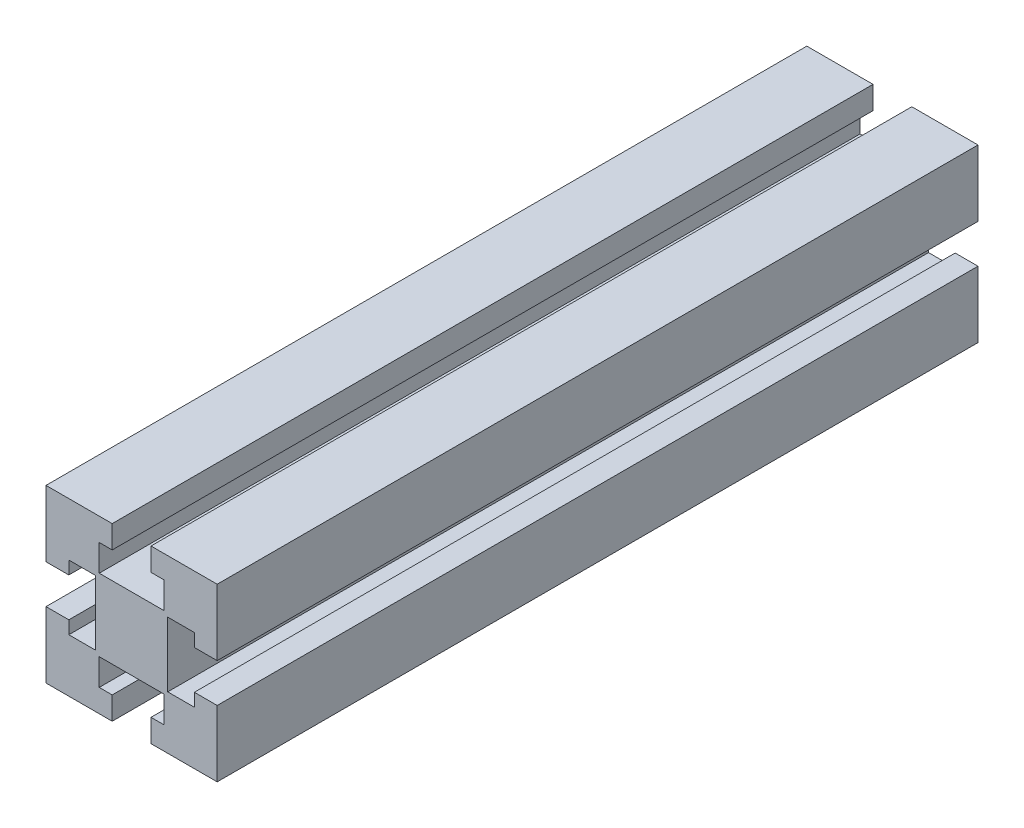
from build123d import *

# Parameters (mm, degrees)
AUFSATZ_LINEAR_AUSTRAGEN1_DEPTH = 200


with BuildPart() as part:
    # Skizze1 → Aufsatz-Linear austragen1 (new body)
    with BuildSketch(Plane.XY):
        Polygon((-18.819236164, 33.776755942), (-1.419236164, 33.776755942), (-1.419236164, 16.376755942), (-7.419236164, 16.376755942), (-7.419236164, 19.781707503), (-14.419236164, 19.781707503), (-14.419236164, 2.77180438), (-7.419236164, 2.77180438), (-7.419236164, 6.176755942), (-1.419236164, 6.176755942), (-1.419236164, -11.223244058), (-18.819236164, -11.223244058), (-18.819236164, -5.223244058), (-15.414284603, -5.223244058), (-15.414284603, 1.776755942), (-32.424187726, 1.776755942), (-32.424187726, -5.223244058), (-29.019236164, -5.223244058), (-29.019236164, -11.223244058), (-46.419236164, -11.223244058), (-46.419236164, 6.176755942), (-40.419236164, 6.176755942), (-40.419236164, 2.77180438), (-33.419236164, 2.77180438), (-33.419236164, 19.781707503), (-40.419236164, 19.781707503), (-40.419236164, 16.376755942), (-46.419236164, 16.376755942), (-46.419236164, 33.776755942), (-29.019236164, 33.776755942), (-29.019236164, 27.776755942), (-32.424187726, 27.776755942), (-32.424187726, 20.776755942), (-15.414284603, 20.776755942), (-15.414284603, 27.776755942), (-18.819236164, 27.776755942), align=None)
    extrude(amount=AUFSATZ_LINEAR_AUSTRAGEN1_DEPTH)


solid = part.part
